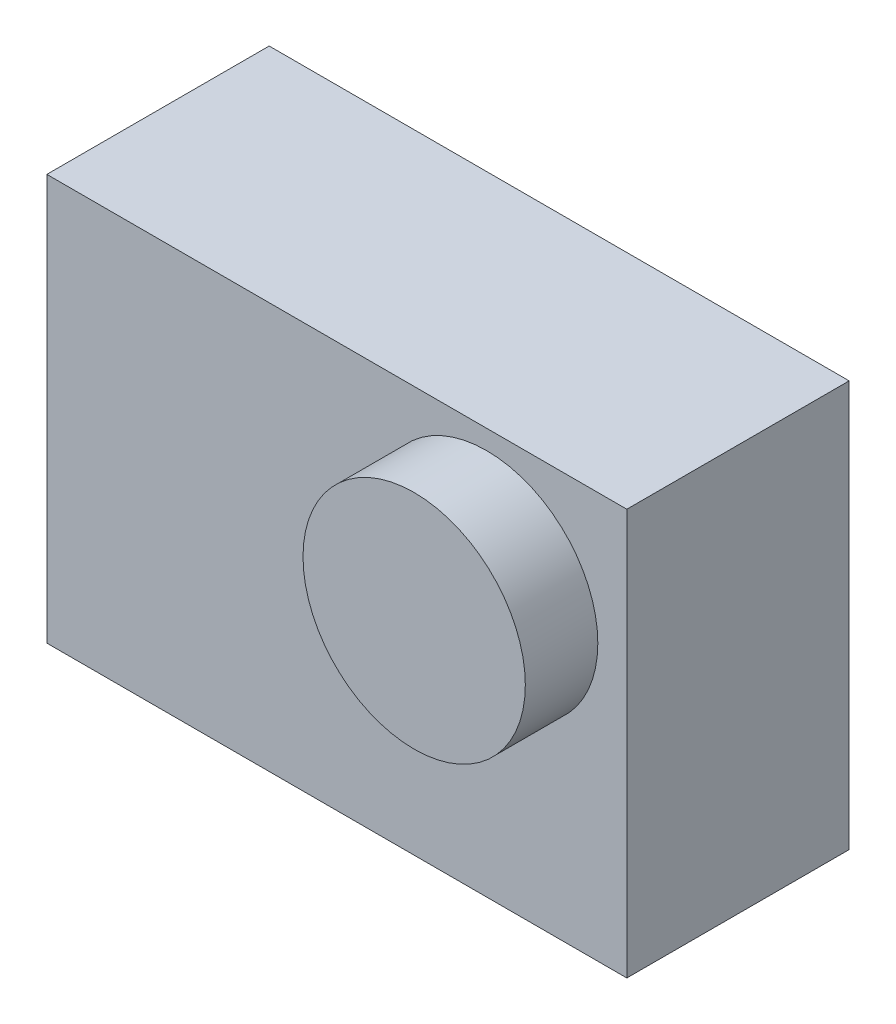
from build123d import *

# Parameters (mm, degrees)
SKETCH_1_W      = 60
SKETCH_1_H      = 42
SKETCH_1_R      = 11.5
EXTRUDE_1_DEPTH = 11.5
EXTRUDE_START   = 11.5
SKETCH_1_3_R    = 11.5
EXTRUDE_2_DEPTH = 7.5


with BuildPart() as part:
    # Эскиз1 → Бобышка-Вытянуть1 (new, symmetric)
    with BuildSketch(Plane.XY):
        Rectangle(SKETCH_1_W, SKETCH_1_H)
        with Locations((15.5, 7.5)):
            Circle(SKETCH_1_R, mode=Mode.SUBTRACT)
        with Locations((15.5, 7.5)):
            Circle(SKETCH_1_R)
    extrude(amount=EXTRUDE_1_DEPTH, both=True)

    # Эскиз1<3> → Бобышка-Вытянуть2 (add)
    with BuildSketch(Plane.XY.offset(EXTRUDE_START)):
        with Locations((15.5, 7.5)):
            Circle(SKETCH_1_3_R)
    extrude(amount=EXTRUDE_2_DEPTH)


solid = part.part
